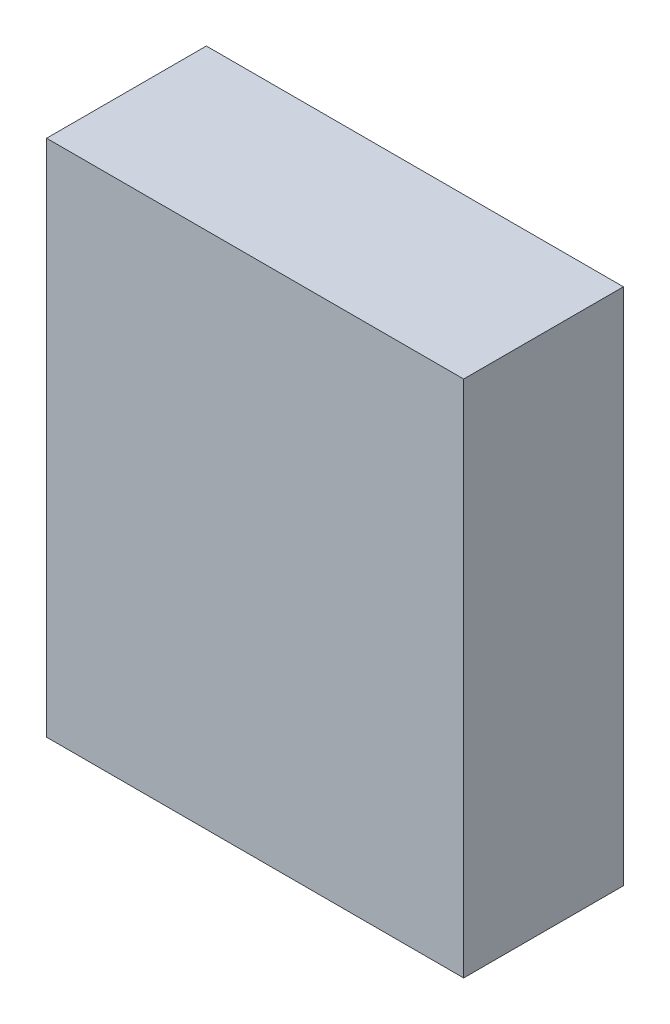
from build123d import *

# Parameters (mm, degrees)
SKETCH1_W               = 2.611
SKETCH1_H               = 3.2475
COMPONENT_OUTLINE_DEPTH = 1


with BuildPart() as part:
    # Sketch1 → Component_Outline (new body)
    with BuildSketch(Plane.XY):
        with Locations((0, 0.03175)):
            Rectangle(SKETCH1_W, SKETCH1_H)
    extrude(amount=COMPONENT_OUTLINE_DEPTH)


solid = part.part
